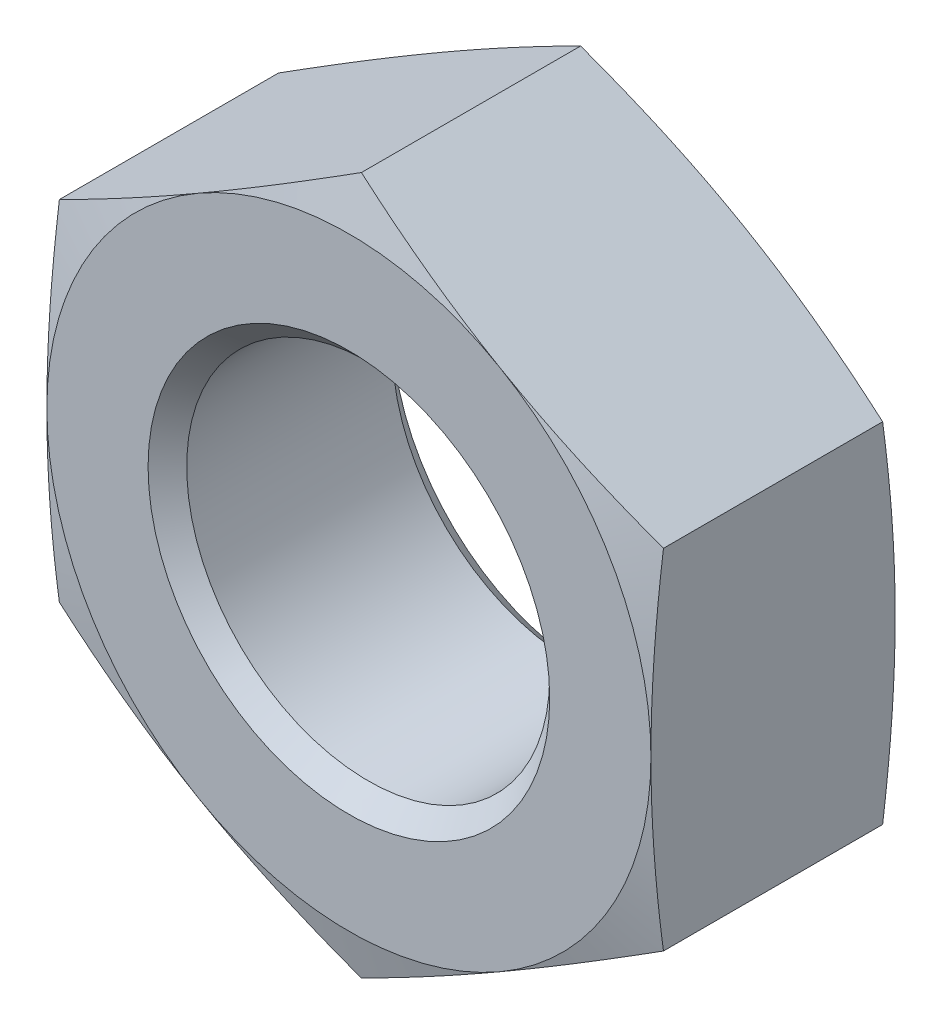
from build123d import *

# Parameters (mm, degrees)
SKETCH2_W          = 47.752
SKETCH2_H          = 47.752
CUT_EXTRUDE1_DEPTH = 9.652


with BuildPart() as part:
    # Sketch1 → Revolve1 (revolve)
    with BuildSketch(Plane(origin=(0, 0, 0), x_dir=(0, 0, -1), z_dir=(1, 0, 0))):
        Polygon((0, 0), (0, 11.938), (0.639755492, 14.3256), (9.012244508, 14.3256), (9.652, 11.938), (9.652, 0), align=None)
    revolve(axis=Axis((0, 0, -9.652), (0, 0, 1)))

    # Sketch2 → Cut-Extrude1 (cut)
    with BuildSketch(Plane.XY):
        Rectangle(SKETCH2_W, SKETCH2_H)
        Polygon((-11.938, -6.892407514), (0, -13.784815027), (11.938, -6.892407514), (11.938, 6.892407514), (0, 13.784815027), (-11.938, 6.892407514), align=None, mode=Mode.SUBTRACT)
    extrude(amount=-CUT_EXTRUDE1_DEPTH, mode=Mode.SUBTRACT)

    # Sketch3 → Cut-Revolve1 (revolve, cut)
    with BuildSketch(Plane(origin=(0, 0, 0), x_dir=(0, 0, -1), z_dir=(1, 0, 0))):
        Polygon((0, 0), (0, 7.9375), (0.76327, 7.17423), (8.88873, 7.17423), (9.652, 7.9375), (9.652, 0), align=None)
    revolve(axis=Axis((0, 0, -9.652), (0, 0, 1)), mode=Mode.SUBTRACT)


solid = part.part
